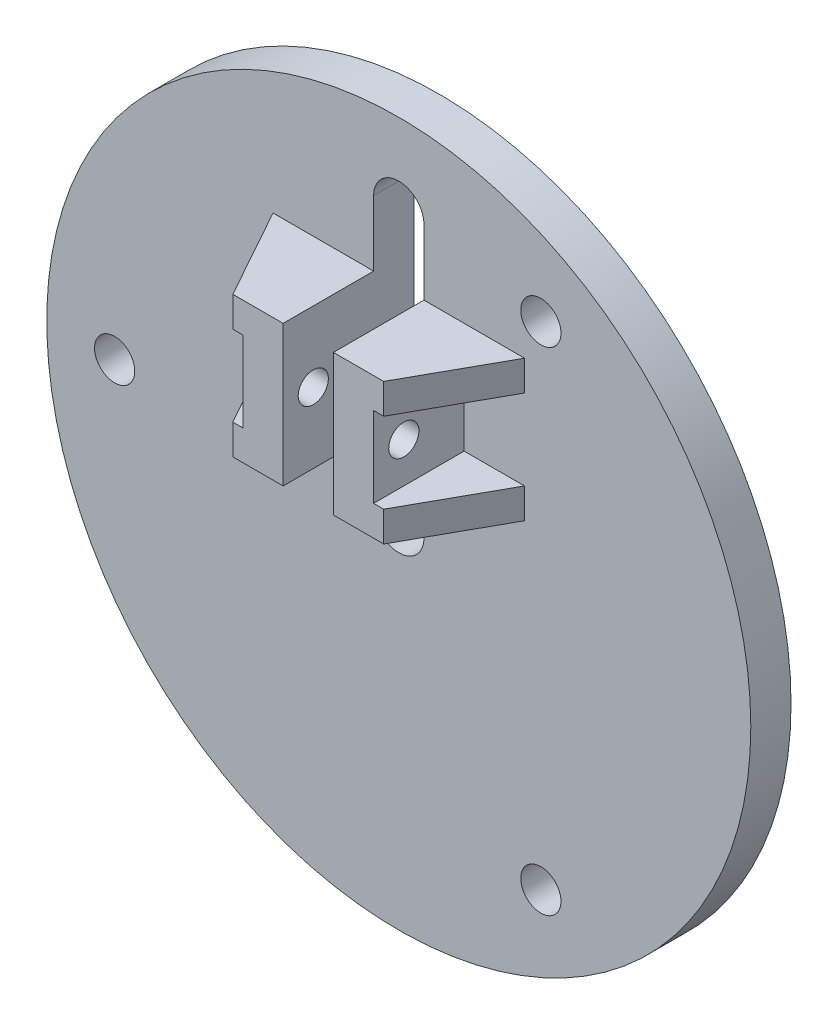
from build123d import *

# Parameters (mm, degrees)
SKETCH_1_R          = 35
SKETCH_1_R_2        = 2
EXTRUDE_1_DEPTH     = 4
EXTRUDE_2_DEPTH     = 9
CUT_EXTRUDE_1_DEPTH = 14
SKETCH_4_R          = 1.45
CUT_EXTRUDE_2_DEPTH = 13
SKETCH_5_R          = 1.5
CUT_EXTRUDE_3_DEPTH = 13


with BuildPart() as part:
    # 草图1 → 凸台-拉伸1 (new body)
    with BuildSketch(Plane.XY):
        Circle(SKETCH_1_R)
        with Locations((14.125, 24.465217657)):
            Circle(SKETCH_1_R_2, mode=Mode.SUBTRACT)
        with Locations((14.125, -24.465217657)):
            Circle(SKETCH_1_R_2, mode=Mode.SUBTRACT)
        with Locations((-28.25, 0)):
            Circle(SKETCH_1_R_2, mode=Mode.SUBTRACT)
        with BuildLine():
            Line((-2.5, 0), (-2.5, 27))
            ThreePointArc((-2.5, 27), (0, 29.5), (2.5, 27))
            Line((2.5, 27), (2.5, 0))
            ThreePointArc((2.5, 0), (0, -2.5), (-2.5, 0))
        make_face(mode=Mode.SUBTRACT)
    extrude(amount=EXTRUDE_1_DEPTH)

    # 草图2 → 凸台-拉伸2 (add)
    with BuildSketch(Plane.XY.offset(4)):
        Polygon((-2.5, 13.5), (-2.5, 20.5), (-12.5, 20.5), (-12.5, 17.5), (-6.5, 17.5), (-6.5, 9.5), (-12.5, 9.5), (-12.5, 6.5), (-2.5, 6.5), align=None)
        Polygon((2.5, 6.5), (2.5, 13.5), (2.5, 20.5), (12.5, 20.5), (12.5, 17.5), (6.5, 17.5), (6.5, 9.5), (12.5, 9.5), (12.5, 6.5), align=None)
    extrude(amount=EXTRUDE_2_DEPTH)

    # 草图3 → 切除-拉伸1 (cut)
    with BuildSketch(Plane.XZ.offset(-6.5)):
        Polygon((-12.5, 4), (-12.5, 13), (-7.5, 13), align=None)
        Polygon((12.5, 4), (12.5, 13), (7.5, 13), align=None)
    extrude(amount=-CUT_EXTRUDE_1_DEPTH, mode=Mode.SUBTRACT)

    # 草图4 → 切除-拉伸2 (cut)
    with BuildSketch(Plane.ZY.offset(6.5)):
        with Locations((10, 13.5)):
            Circle(SKETCH_4_R)
    extrude(amount=-CUT_EXTRUDE_2_DEPTH, mode=Mode.SUBTRACT)

    # 草图5 → 切除-拉伸3 (cut)
    with BuildSketch(Plane(origin=(6.5, 0, 0), x_dir=(0, 0, -1), z_dir=(1, 0, 0))):
        with Locations((-10, 13.5)):
            Circle(SKETCH_5_R)
    extrude(amount=-CUT_EXTRUDE_3_DEPTH, mode=Mode.SUBTRACT)


solid = part.part
